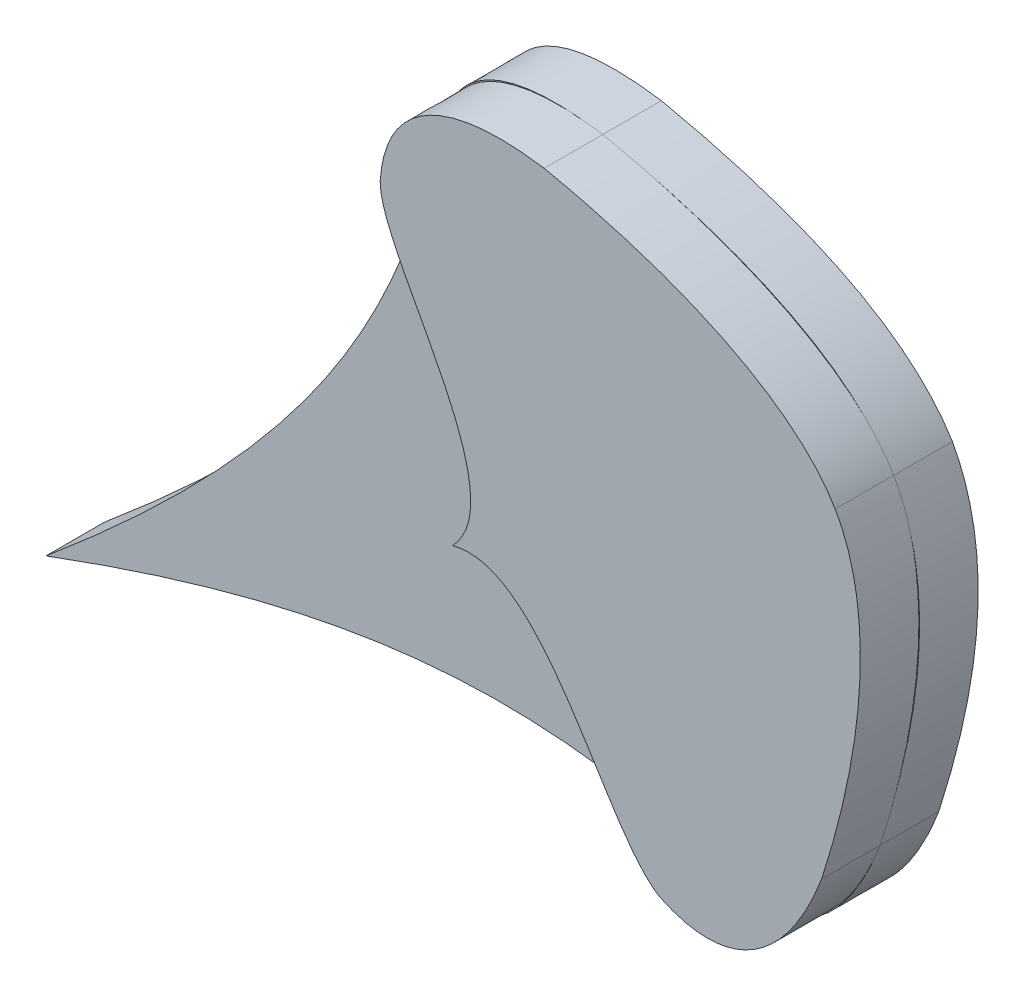
from build123d import *

# Parameters (mm, degrees)
BOSS_EXTRUDE1_DEPTH = 10
BOSS_EXTRUDE2_DEPTH = 10


with BuildPart() as part:
    # Sketch1 → Boss-Extrude1 (new body)
    with BuildSketch(Plane.XY):
        with BuildLine():
            add(Edge.make_bspline(
                [(1087.187780825, 840.59586504), (1076.67910482, 857.874790108), (1037.516605064, 866.140022112)],
                knots=[0, 0, 0, 1, 1, 1], degree=2))
            add(Edge.make_bspline(
                [(1037.516605064, 866.140022112), (1011.295592155, 870.066211203), (1009.525576357, 850.301034786)],
                knots=[0, 0, 0, 1, 1, 1], degree=2))
            add(Edge.make_bspline(
                [(1009.525576357, 850.301034786), (1001.907342818, 820.670179882), (988.206449115, 794.709110121), (942.482736763, 756.327533098)],
                knots=[0, 0, 0, 0, 1, 1, 1, 1], degree=3))
            add(Edge.make_bspline(
                [(1057.301588716, 768.260369991), (1027.770781215, 776.257647836), (998.429870334, 777.153516176), (942.482736763, 756.327533098)],
                knots=[0, 0, 0, 0, 1, 1, 1, 1], degree=3))
            add(Edge.make_bspline(
                [(1084.891265336, 784.788556571), (1075.365665589, 760.045488285), (1057.301588716, 768.260369991)],
                knots=[0, 0, 0, 1, 1, 1], degree=2))
            add(Edge.make_bspline(
                [(1087.187780825, 840.59586504), (1097.029795788, 822.928712911), (1084.891265336, 784.788556571)],
                knots=[0, 0, 0, 1, 1, 1], degree=2))
        make_face()
    extrude(amount=BOSS_EXTRUDE1_DEPTH)

    # Sketch3 → Boss-Extrude2 (add)
    with BuildSketch(Plane.XY.offset(10)):
        with BuildLine():
            add(Edge.make_bspline(
                [(1087.187780825, 840.59586504), (1081.487119197, 850.529819758), (1065.232454637, 860.336996081), (1037.516605064, 866.140022112)],
                knots=[0, 0, 0, 0, 1, 1, 1, 1], degree=3))
            add(Edge.make_bspline(
                [(1037.516605064, 866.140022112), (1020.004409568, 868.813580173), (1010.347971001, 862.587896026), (1009.525576357, 850.301034786)],
                knots=[0, 0, 0, 0, 1, 1, 1, 1], degree=3))
            add(Edge.make_bspline(
                [(1009.525576357, 850.301034786), (1009.355347436, 839.605465182), (1033.361525181, 814.302214514), (1021.863356533, 802.554480195)],
                knots=[0, 0, 0, 0, 1, 1, 1, 1], degree=3))
            add(Edge.make_bspline(
                [(1057.301588716, 768.260369991), (1047.915219632, 773.390697705), (1037.755299032, 806.75725398), (1021.863356533, 802.554480195)],
                knots=[0, 0, 0, 0, 1, 1, 1, 1], degree=3))
            add(Edge.make_bspline(
                [(1084.891265336, 784.788556571), (1078.57410115, 768.238078014), (1068.393818008, 762.911936443), (1057.301588716, 768.260369991)],
                knots=[0, 0, 0, 0, 1, 1, 1, 1], degree=3))
            add(Edge.make_bspline(
                [(1087.187780825, 840.59586504), (1093.014393603, 830.735257407), (1093.522224403, 811.757983228), (1084.891265336, 784.788556571)],
                knots=[0, 0, 0, 0, 1, 1, 1, 1], degree=3))
        make_face()
    extrude(amount=BOSS_EXTRUDE2_DEPTH)


solid = part.part
